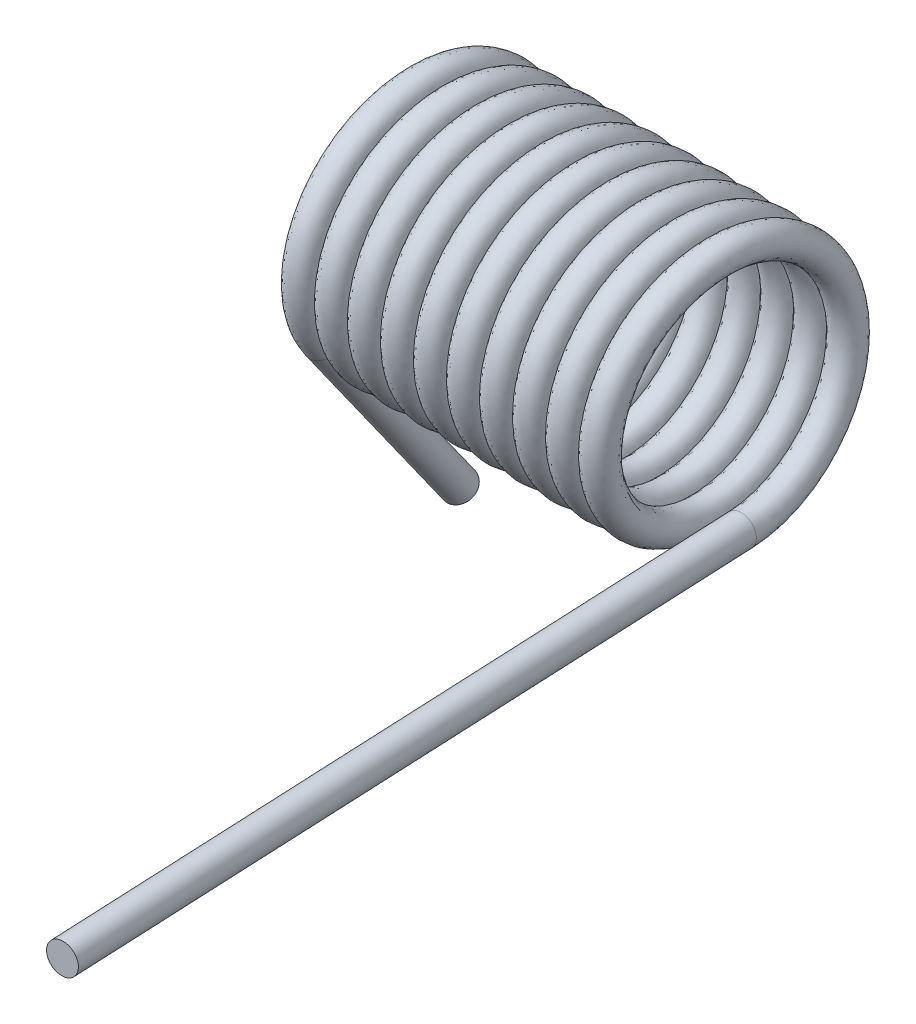
from build123d import *

# Parameters (mm, degrees)
SWEEP1_PITCH       = 0.3302
SWEEP1_HEIGHT      = 3.25247
SWEEP1_RADIUS      = 1.1557
SWEEP1_START_ANGLE = 90
SKETCH3_R          = 0.1524
SKETCH4_R          = 0.1524
EXTRUDE1_DEPTH     = 7.112
SKETCH5_R          = 0.1524
EXTRUDE2_DEPTH     = 2.54


with BuildPart() as part:
    # Sweep1: sweep along a helix
    with BuildLine() as sweep1_path:
        add(Helix(SWEEP1_PITCH, SWEEP1_HEIGHT, SWEEP1_RADIUS, center=(0, 0, 0), direction=(-1, 0, 0), lefthand=True, mode=Mode.PRIVATE).rotate(Axis((0, 0, 0), (-1, 0, 0)), SWEEP1_START_ANGLE))
    # Sketch3 → Sweep1 (sweep)
    with BuildSketch(Plane(origin=(0, -1.1557, 0), x_dir=(0.998697994, -0.023236129, -0.045413635), z_dir=(-0.0454259, 0, -0.998967711))):
        Circle(SKETCH3_R)
    sweep(path=sweep1_path.line, is_frenet=True)

    # Sketch4 → Extrude1 (add)
    with BuildSketch(Plane(origin=(0, 0, 0), x_dir=(-0.998697994, 0.023236129, 0.045413635), z_dir=(0.0454259, 0, 0.998967711))):
        with Locations((-0.026853994, 1.155387966)):
            Circle(SKETCH4_R)
    extrude(amount=EXTRUDE1_DEPTH)

    # Sketch5 → Extrude2 (add)
    with BuildSketch(Plane(origin=(-0.006711512, -0.11940594, -0.086753494), x_dir=(0.9527613, 0.141646097, -0.268667616), z_dir=(-0.0454259, -0.808181855, -0.587178488))):
        with Locations((-3.446247324, 0.125514859)):
            Circle(SKETCH5_R)
    extrude(amount=EXTRUDE2_DEPTH)


solid = part.part
